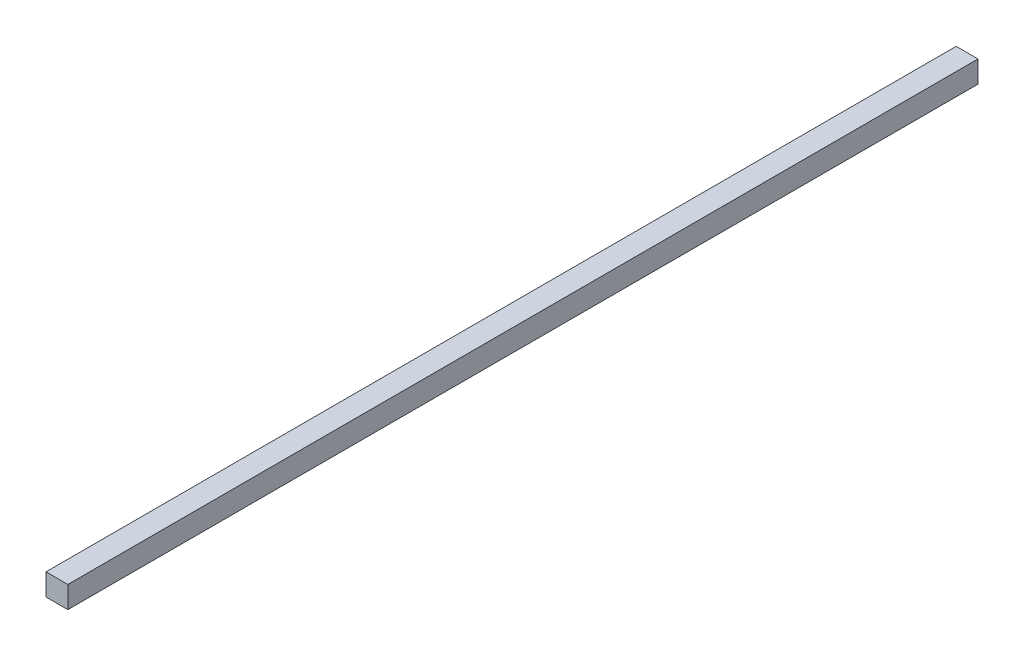
from build123d import *

# Parameters (mm, degrees)
ESQUISSE1_W      = 18
ESQUISSE1_H      = 18
EXTRUSION1_DEPTH = 750


with BuildPart() as part:
    # Esquisse1 → Extrusion1 (new body)
    with BuildSketch(Plane.XY):
        with Locations((9, 9)):
            Rectangle(ESQUISSE1_W, ESQUISSE1_H)
    extrude(amount=-EXTRUSION1_DEPTH)


solid = part.part
